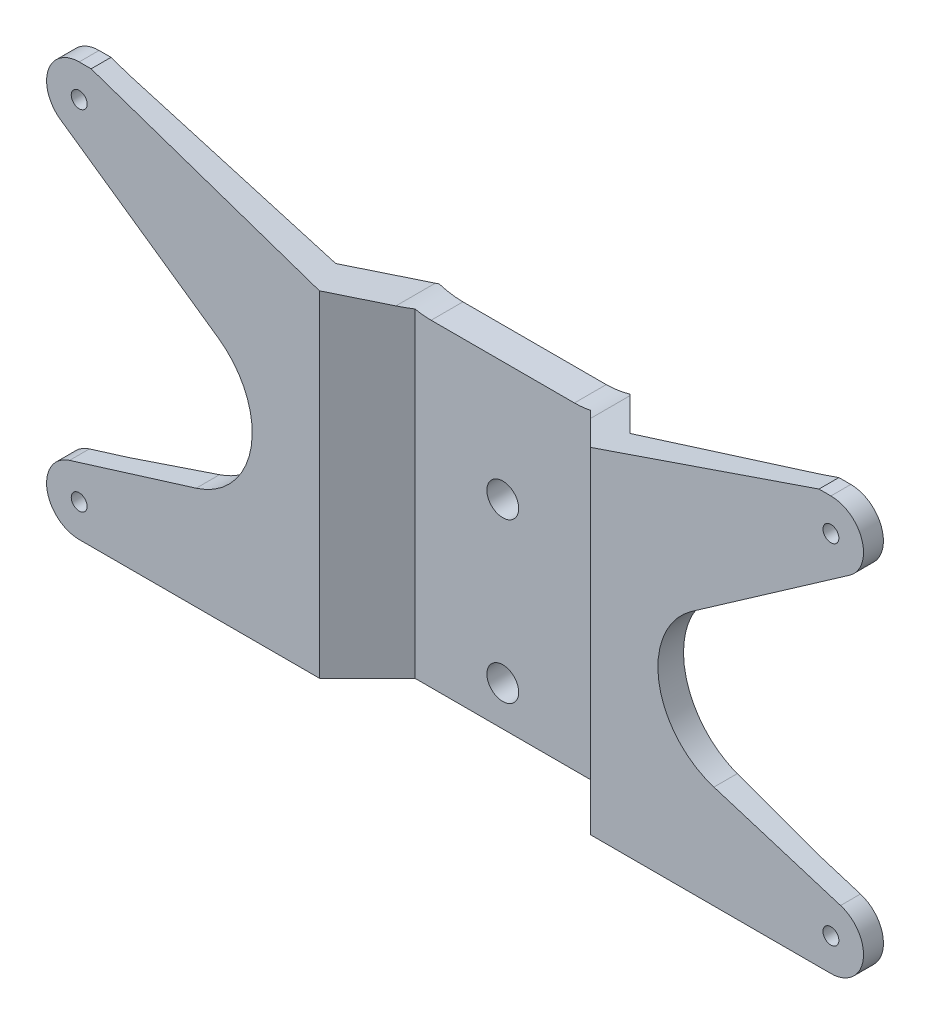
from build123d import *

# Parameters (mm, degrees)
BOSS_EXTRUDE1_DEPTH = 52
SKETCH2_R           = 1
CUT_EXTRUDE1_DEPTH  = 11
SKETCH3_R           = 2
CUT_EXTRUDE2_DEPTH  = 5


with BuildPart() as part:
    # Sketch1 → Boss-Extrude1 (new body)
    with BuildSketch(Plane(origin=(0, 0, 0), x_dir=(1, 0, 0), z_dir=(0, 1, 0))):
        Polygon((0, 0), (0, -4), (11.050252532, -4), (17.050252532, -10), (51.5, -10), (51.5, -7.5), (43.5, -7.5), (18.5, -6.5), (12, 0), align=None)
    extrude(amount=BOSS_EXTRUDE1_DEPTH)

    # Sketch2 → Cut-Extrude1 (cut, through all)
    with BuildSketch(Plane.XY.offset(10)):
        with Locations((47.25, 47.9)):
            Circle(SKETCH2_R)
        with Locations((47.25, 4.1)):
            Circle(SKETCH2_R)
        with BuildLine():
            Line((45.75, 52), (0, 52))
            Line((0, 52), (0, 40))
            Line((0, 40), (9.006487072, 40))
            ThreePointArc((9.006487072, 40), (10.647005463, 40.135482809), (12.243071445, 40.538260118))
            Line((12.243071445, 40.538260118), (45.75, 52))
        make_face()
        with BuildLine():
            Line((49.597069908, 44.538264905), (29.77543925, 30.69935389))
            ThreePointArc((29.77543925, 30.69935389), (25.619228249, 20.960406025), (32.541456651, 12.947669329))
            Line((32.541456651, 12.947669329), (48.463002773, 8.016455575))
            ThreePointArc((48.463002773, 8.016455575), (51.303854207, 3.486594693), (47.25, 0))
            Line((47.25, 0), (51.5, 0))
            Line((51.5, 0), (51.5, 52))
            Line((51.5, 52), (47.25, 52))
            ThreePointArc((47.25, 52), (51.161081301, 49.130220734), (49.597069908, 44.538264905))
        make_face()
    extrude(amount=-CUT_EXTRUDE1_DEPTH, mode=Mode.SUBTRACT)

    # Mirror1: part across plane


with BuildPart() as part_1:
    add(part.part)
    add(part.part.mirror(Plane(origin=(0, 52, 0), x_dir=(0, 0, 1), z_dir=(1, 0, 0))))

    # Sketch3 → Cut-Extrude2 (cut, through all)
    with BuildSketch(Plane.XY.offset(4)):
        with Locations((0, 5)):
            Circle(SKETCH3_R)
        with Locations((0, 25)):
            Circle(SKETCH3_R)
    extrude(amount=-CUT_EXTRUDE2_DEPTH, mode=Mode.SUBTRACT)


solid = part_1.part
